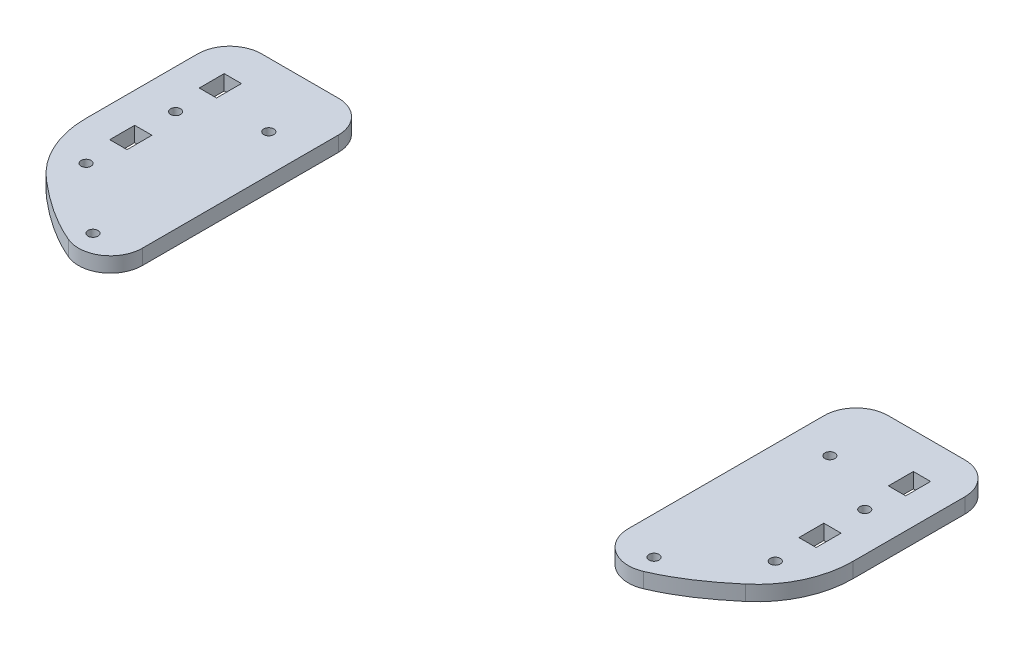
from build123d import *

# Parameters (mm, degrees)
SKETCH1_R        = 1.984375
SKETCH1_W        = 6.858
SKETCH1_H        = 9.906
EXTRUDE1_DEPTH   = 5.9944
EXTRUDE1_2_DEPTH = 5.9944
FILLET1_R        = 12.7
FILLET2_R        = 12.7
FILLET3_R        = 12.7
FILLET5_R        = 12.7
FILLET6_R        = 12.7
FILLET7_R        = 38.1
FILLET8_R        = 38.1
FILLET9_R        = 12.7


with BuildPart() as part:
    # Sketch1 → Extrude1 (new body)
    with BuildSketch(Plane(origin=(0, 0, 0), x_dir=(1, 0, 0), z_dir=(0, 1, 0))):
        with BuildLine():
            Line((38.251531685, 0), (-17.628468315, 0))
            Line((-17.628468315, 0), (-17.628468315, -74.142996555))
            add(Edge.make_bspline(
                [(-17.628468315, -74.142996555), (-7.183046663, -83.85534331), (9.286812039, -99.169323354), (30.494181461, -106.074935248), (38.251531685, -108.600908597)],
                knots=[0, 0, 0, 0, 0.634214406, 1, 1, 1, 1], degree=3))
            Line((38.251531685, -108.600908597), (38.251531685, 0))
        make_face()
        with Locations((23.306531685, -95.25)):
            Circle(SKETCH1_R, mode=Mode.SUBTRACT)
        with Locations((-2.134468315, -72.531002397)):
            Circle(SKETCH1_R, mode=Mode.SUBTRACT)
        with Locations((-2.134468315, -54.751002397)):
            Rectangle(SKETCH1_W, SKETCH1_H, mode=Mode.SUBTRACT)
        with Locations((-2.134468315, -36.971002397)):
            Circle(SKETCH1_R, mode=Mode.SUBTRACT)
        with Locations((23.306531685, -25.4)):
            Circle(SKETCH1_R, mode=Mode.SUBTRACT)
        with Locations((-2.134468315, -19.191002397)):
            Rectangle(SKETCH1_W, SKETCH1_H, mode=Mode.SUBTRACT)
    extrude(amount=-EXTRUDE1_DEPTH)

    # Fillet1
    fillet1_edges = [part.edges().sort_by_distance(p)[0] for p in [
        (-17.628468315, -2.9972, 0),
    ]]
    fillet(fillet1_edges, radius=FILLET1_R)

    # Fillet2
    fillet2_edges = [part.edges().sort_by_distance(p)[0] for p in [
        (38.251531685, -2.9972, 0),
    ]]
    fillet(fillet2_edges, radius=FILLET2_R)

    # Fillet6
    fillet6_edges = [part.edges().sort_by_distance(p)[0] for p in [
        (38.251531685, -2.9972, 108.600908597),
    ]]
    fillet(fillet6_edges, radius=FILLET6_R)

    # Fillet7
    fillet7_edges = [part.edges().sort_by_distance(p)[0] for p in [
        (-17.628468315, -2.9972, 74.142996555),
    ]]
    fillet(fillet7_edges, radius=FILLET7_R)


with BuildPart() as body_2:
    # Sketch1 → Extrude1 2 (new body)
    with BuildSketch(Plane(origin=(0, 0, 0), x_dir=(1, 0, 0), z_dir=(0, 1, 0))):
        with BuildLine():
            Line((287.171531685, 0), (231.291531685, 0))
            Line((231.291531685, 0), (231.291531685, -108.600908597))
            add(Edge.make_bspline(
                [(287.171531685, -74.142996555), (276.726110033, -83.85534331), (260.25625133, -99.169323354), (239.048881908, -106.074935248), (231.291531685, -108.600908597)],
                knots=[0, 0, 0, 0, 0.634214406, 1, 1, 1, 1], degree=3))
            Line((287.171531685, -74.142996555), (287.171531685, 0))
        make_face()
        with Locations((246.236531685, -95.25)):
            Circle(SKETCH1_R, mode=Mode.SUBTRACT)
        with Locations((271.677531685, -72.531002397)):
            Circle(SKETCH1_R, mode=Mode.SUBTRACT)
        with Locations((271.677531685, -54.751002397)):
            Rectangle(SKETCH1_W, SKETCH1_H, mode=Mode.SUBTRACT)
        with Locations((246.236531685, -25.4)):
            Circle(SKETCH1_R, mode=Mode.SUBTRACT)
        with Locations((271.677531685, -36.971002397)):
            Circle(SKETCH1_R, mode=Mode.SUBTRACT)
        with Locations((271.677531685, -19.191002397)):
            Rectangle(SKETCH1_W, SKETCH1_H, mode=Mode.SUBTRACT)
    extrude(amount=-EXTRUDE1_2_DEPTH)

    # Fillet3
    fillet3_edges = [body_2.edges().sort_by_distance(p)[0] for p in [
        (287.171531685, -2.9972, 0),
    ]]
    fillet(fillet3_edges, radius=FILLET3_R)

    # Fillet5
    fillet5_edges = [body_2.edges().sort_by_distance(p)[0] for p in [
        (231.291531685, -2.9972, 0),
    ]]
    fillet(fillet5_edges, radius=FILLET5_R)

    # Fillet8
    fillet8_edges = [body_2.edges().sort_by_distance(p)[0] for p in [
        (287.171531685, -2.9972, 74.142996555),
    ]]
    fillet(fillet8_edges, radius=FILLET8_R)

    # Fillet9
    fillet9_edges = [body_2.edges().sort_by_distance(p)[0] for p in [
        (231.291531685, -2.9972, 108.600908597),
    ]]
    fillet(fillet9_edges, radius=FILLET9_R)


solid = Compound([part.part, body_2.part])
